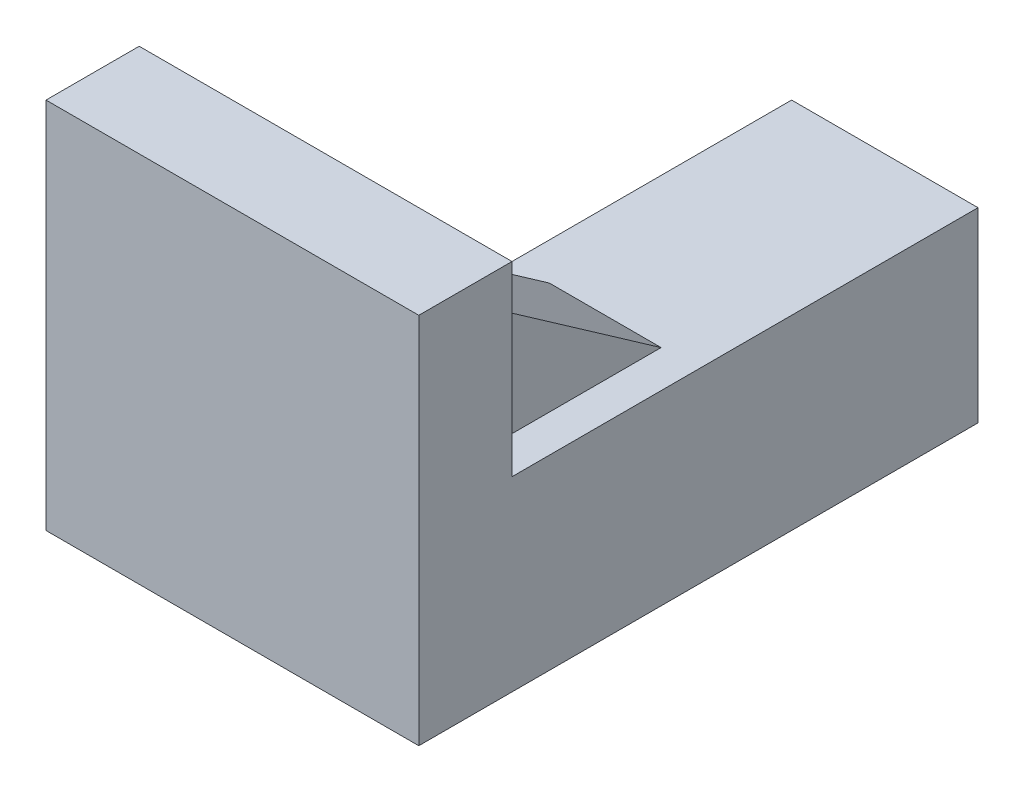
from build123d import *

# Parameters (mm, degrees)
SKETCH_1_W          = 10
SKETCH_1_H          = 10
EXTRUDE_1_DEPTH     = 25
SKETCH_2_R          = 1.5
CUT_EXTRUDE_1_DEPTH = 15
SKETCH_3_W          = 20
SKETCH_3_H          = 20
EXTRUDE_2_DEPTH     = 5
SKETCH_4_W          = 7
SKETCH_4_H          = 3
SKETCH_4_W_2        = 3
SKETCH_4_H_2        = 7
EXTRUDE_3_DEPTH     = 10
CUT_EXTRUDE_2_DEPTH = 10
CUT_EXTRUDE_3_DEPTH = 10


with BuildPart() as part:
    # 草图1 → 凸台-拉伸1 (new body)
    with BuildSketch(Plane.XY):
        with Locations((5, 5)):
            Rectangle(SKETCH_1_W, SKETCH_1_H)
    extrude(amount=EXTRUDE_1_DEPTH)

    # 草图2 → 切除-拉伸1 (cut)
    with BuildSketch(Plane(origin=(0, 0, 0), x_dir=(-1, 0, 0), z_dir=(0, 0, -1))):
        with Locations((-5.707106781, 4.292893219)):
            Circle(SKETCH_2_R)
    extrude(amount=-CUT_EXTRUDE_1_DEPTH, mode=Mode.SUBTRACT)

    # 草图3 → 凸台-拉伸2 (add)
    with BuildSketch(Plane.XY.offset(25)):
        with Locations((0, 10)):
            Rectangle(SKETCH_3_W, SKETCH_3_H)
    extrude(amount=EXTRUDE_2_DEPTH)

    # 草图4 → 凸台-拉伸3 (add)
    with BuildSketch(Plane(origin=(0, 0, 25), x_dir=(-1, 0, 0), z_dir=(0, 0, -1))):
        with Locations((3.5, 6.5)):
            Rectangle(SKETCH_4_W, SKETCH_4_H)
        with Locations((3.5, 3.5)):
            Rectangle(SKETCH_4_W, SKETCH_4_H)
        with Locations((-3.5, 13.5)):
            Rectangle(SKETCH_4_W_2, SKETCH_4_H_2)
        with Locations((-6.5, 13.5)):
            Rectangle(SKETCH_4_W_2, SKETCH_4_H_2)
    extrude(amount=EXTRUDE_3_DEPTH)

    # 草图5 → 切除-拉伸2 (cut)
    with BuildSketch(Plane(origin=(0, 8, 0), x_dir=(1, 0, 0), z_dir=(0, 1, 0))):
        Polygon((-7, -25), (0, -15), (-7, -15), align=None)
    extrude(amount=-CUT_EXTRUDE_2_DEPTH, mode=Mode.SUBTRACT)

    # 草图6 → 切除-拉伸3 (cut)
    with BuildSketch(Plane.ZY.offset(-2)):
        Polygon((15, 10), (25, 17), (15, 17), align=None)
    extrude(amount=-CUT_EXTRUDE_3_DEPTH, mode=Mode.SUBTRACT)


solid = part.part
